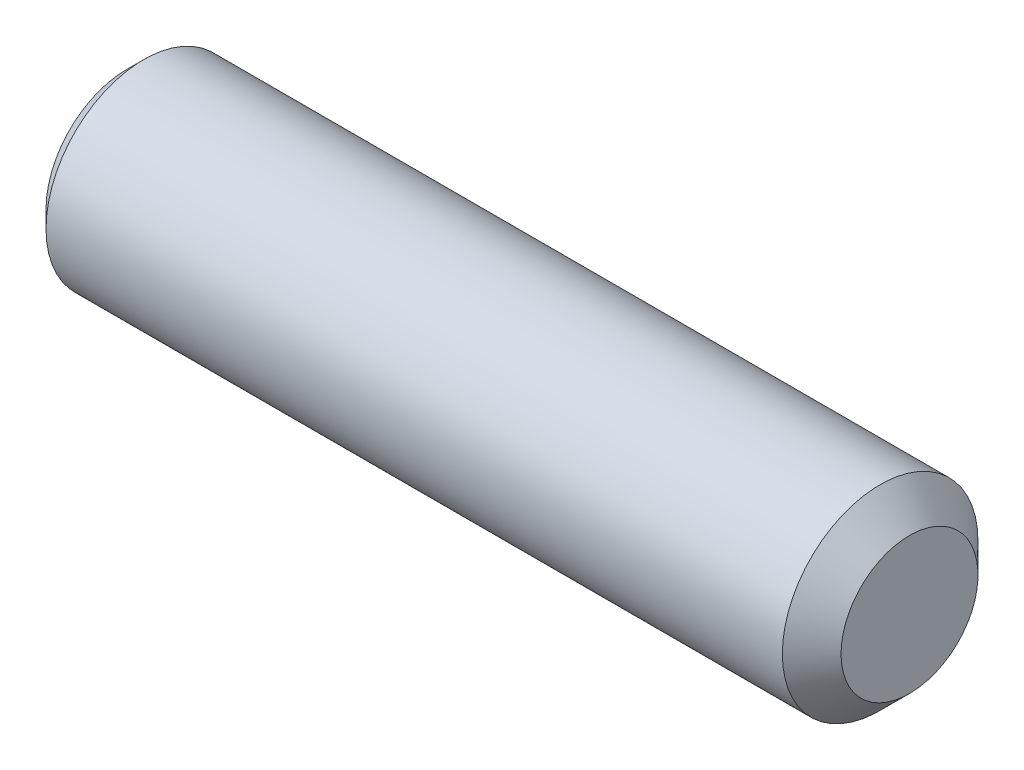
from build123d import *

# Parameters (mm, degrees)
HEXAGONSOCKET_DEPTH = 2


with BuildPart() as part:
    # Sketch1 → Base (revolve)
    with BuildSketch(Plane.XY):
        Polygon((0, 0), (20, 0), (20, 1.75), (19.25, 2.5), (0.433, 2.5), (0, 2.067), align=None)
    revolve(axis=Axis((-10.745014543, 0, 0), (1, 0, 0)))

    # Sketch2 → HexagonSocket (cut)
    with BuildSketch(Plane(origin=(0, -0.021932325, 0.010138848), x_dir=(0, 0, 1), z_dir=(-1, 0, 0))):
        Polygon((1.433236825, 0.021932325), (0.711548988, 1.271932325), (-0.731826685, 1.271932325), (-1.453514521, 0.021932325), (-0.731826685, -1.228067675), (0.711548988, -1.228067675), align=None)
    extrude(amount=-HEXAGONSOCKET_DEPTH, mode=Mode.SUBTRACT)

    # Sketch3 → Cut-Revolve1 (revolve, cut)
    with BuildSketch(Plane.XY):
        Polygon((2, 1.25), (2.721687837, 0), (2, 0), align=None)
    revolve(axis=Axis((-3.144113667, 0, 0), (1, 0, 0)), mode=Mode.SUBTRACT)


solid = part.part
